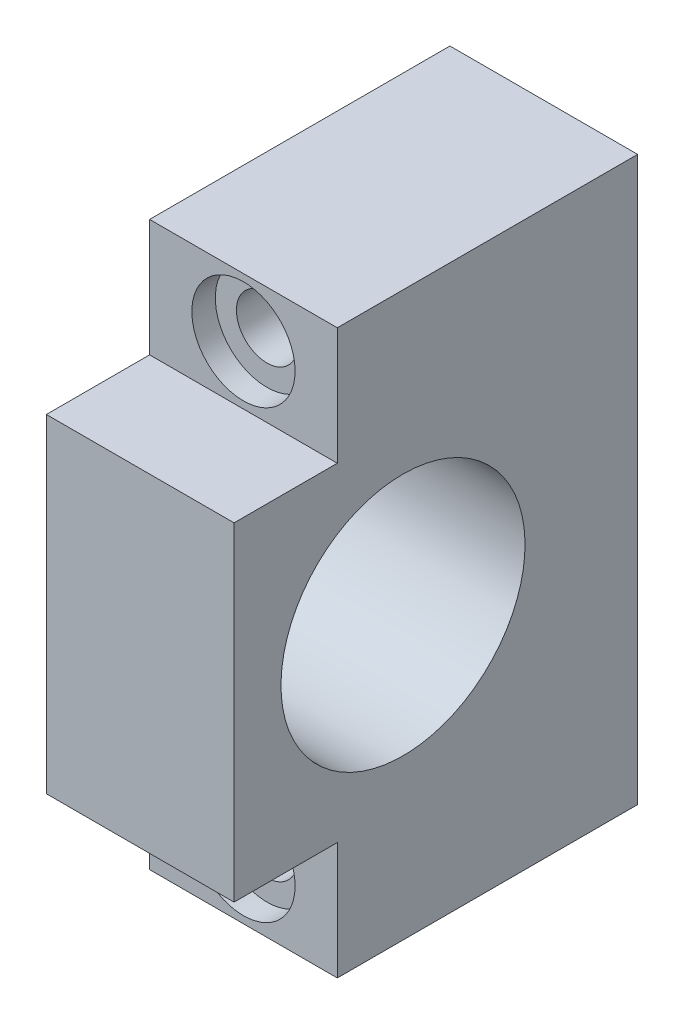
from build123d import *

# Parameters (mm, degrees)
SKETCH1_W           = 20
SKETCH1_H           = 60
BOSS_EXTRUDE1_DEPTH = 43
SKETCH2_W           = 20
SKETCH2_H           = 12.5
CUT_EXTRUDE1_DEPTH  = 11
SKETCH3_R           = 3.25
CUT_EXTRUDE2_DEPTH  = 33
SKETCH4_R           = 5.5
CUT_EXTRUDE3_DEPTH  = 2.5
SKETCH5_R           = 13
CUT_EXTRUDE4_DEPTH  = 21


with BuildPart() as part:
    # Sketch1 → Boss-Extrude1 (new body)
    with BuildSketch(Plane.XY):
        Rectangle(SKETCH1_W, SKETCH1_H)
    extrude(amount=BOSS_EXTRUDE1_DEPTH)

    # Sketch2 → Cut-Extrude1 (cut)
    with BuildSketch(Plane.XY.offset(43)):
        with Locations((0, -23.75)):
            Rectangle(SKETCH2_W, SKETCH2_H)
        with Locations((0, 23.75)):
            Rectangle(SKETCH2_W, SKETCH2_H)
    extrude(amount=-CUT_EXTRUDE1_DEPTH, mode=Mode.SUBTRACT)

    # Sketch3 → Cut-Extrude2 (cut, through all)
    with BuildSketch(Plane.XY.offset(32)):
        with Locations((0, -23.75)):
            Circle(SKETCH3_R)
        with Locations((0, 23.75)):
            Circle(SKETCH3_R)
    extrude(amount=-CUT_EXTRUDE2_DEPTH, mode=Mode.SUBTRACT)

    # Sketch4 → Cut-Extrude3 (cut)
    with BuildSketch(Plane.XY.offset(32)):
        with Locations((0, -23.75)):
            Circle(SKETCH4_R)
        with Locations((0, 23.75)):
            Circle(SKETCH4_R)
    extrude(amount=-CUT_EXTRUDE3_DEPTH, mode=Mode.SUBTRACT)

    # Sketch5 → Cut-Extrude4 (cut, through all)
    with BuildSketch(Plane(origin=(10, 0, 0), x_dir=(0, 0, -1), z_dir=(1, 0, 0))):
        with Locations((-25, 0)):
            Circle(SKETCH5_R)
    extrude(amount=-CUT_EXTRUDE4_DEPTH, mode=Mode.SUBTRACT)


solid = part.part
